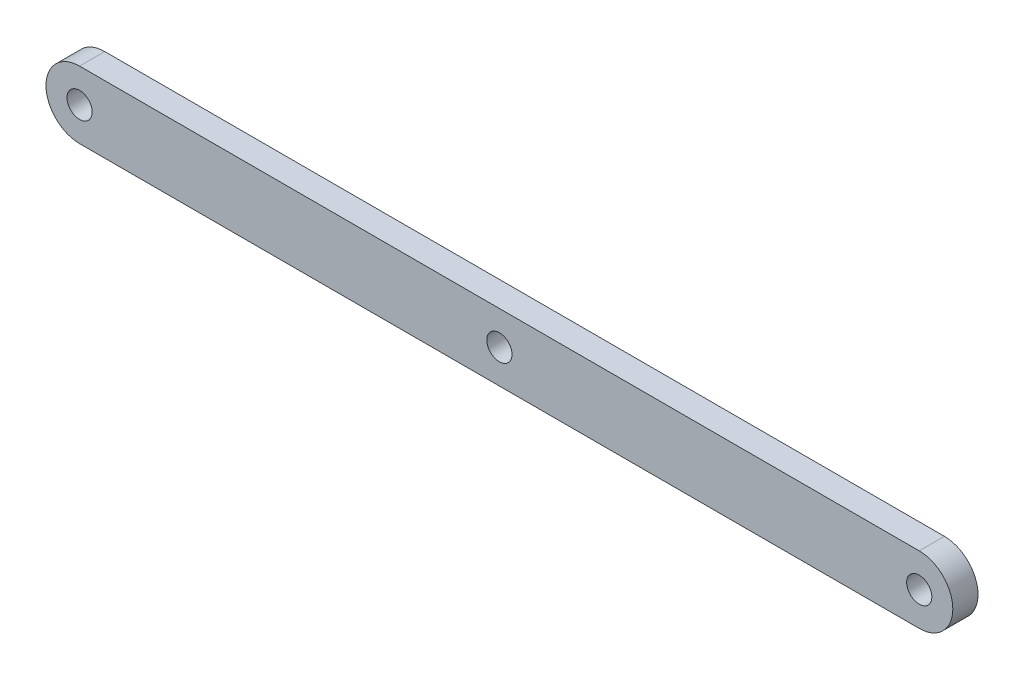
from build123d import *

# Parameters (mm, degrees)
SKETCH1_R           = 1.5
BOSS_EXTRUDE1_DEPTH = 3


with BuildPart() as part:
    # Sketch1 → Boss-Extrude1 (new body)
    with BuildSketch(Plane.XY):
        with BuildLine():
            Line((-50, -4), (50, -4))
            ThreePointArc((50, -4), (54, 0), (50, 4))
            Line((50, 4), (-50, 4))
            ThreePointArc((-50, 4), (-54, 0), (-50, -4))
        make_face()
        with Locations((-50, 0)):
            Circle(SKETCH1_R, mode=Mode.SUBTRACT)
        Circle(SKETCH1_R, mode=Mode.SUBTRACT)
        with Locations((50, 0)):
            Circle(SKETCH1_R, mode=Mode.SUBTRACT)
    extrude(amount=BOSS_EXTRUDE1_DEPTH)


solid = part.part
